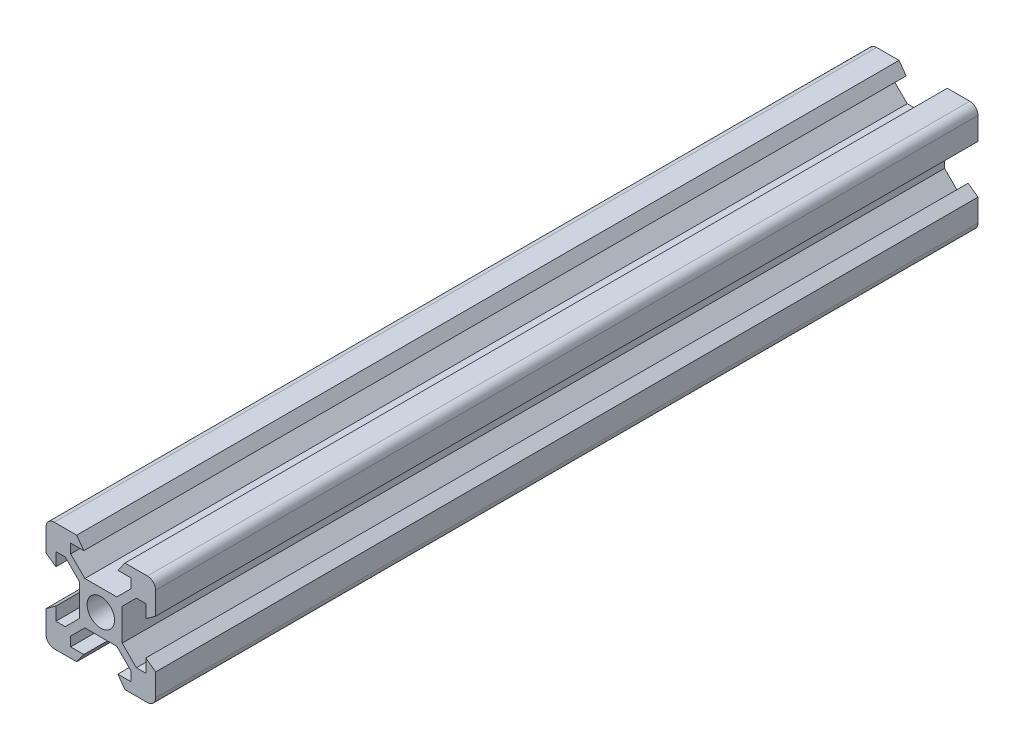
from build123d import *

# Parameters (mm, degrees)
SKETCH_1_R      = 2.5
EXTRUDE_1_DEPTH = 150


with BuildPart() as part:
    # 草图1 → 凸台-拉伸1 (new body)
    with BuildSketch(Plane.XY):
        with BuildLine():
            Line((14.8, 34.821428571), (18.9, 34.821428571))
            Line((18.9, 34.821428571), (20.2, 33.021428571))
            Line((20.2, 33.021428571), (17.8, 33.021428571))
            Line((17.8, 33.021428571), (17.8, 31.311378065))
            Line((17.8, 31.311378065), (20.389949494, 28.721428571))
            Line((20.389949494, 28.721428571), (26.210050506, 28.721428571))
            Line((26.210050506, 28.721428571), (28.8, 31.311378065))
            Line((28.8, 31.311378065), (28.8, 33.021428571))
            Line((28.8, 33.021428571), (26.4, 33.021428571))
            Line((26.4, 33.021428571), (27.7, 34.821428571))
            Line((27.7, 34.821428571), (31.8, 34.821428571))
            ThreePointArc((31.8, 34.821428571), (32.860660172, 34.382088743), (33.3, 33.321428571))
            Line((33.3, 33.321428571), (33.3, 29.221428571))
            Line((33.3, 29.221428571), (31.5, 27.921428571))
            Line((31.5, 27.921428571), (31.5, 30.321428571))
            Line((31.5, 30.321428571), (29.789949494, 30.321428571))
            Line((29.789949494, 30.321428571), (27.2, 27.731479078))
            Line((27.2, 27.731479078), (27.2, 21.911378065))
            Line((27.2, 21.911378065), (29.789949494, 19.321428571))
            Line((29.789949494, 19.321428571), (31.5, 19.321428571))
            Line((31.5, 19.321428571), (31.5, 21.721428571))
            Line((31.5, 21.721428571), (33.3, 20.421428571))
            Line((33.3, 20.421428571), (33.3, 16.321428571))
            ThreePointArc((33.3, 16.321428571), (32.860660172, 15.2607684), (31.8, 14.821428571))
            Line((31.8, 14.821428571), (27.7, 14.821428571))
            Line((27.7, 14.821428571), (26.4, 16.621428571))
            Line((26.4, 16.621428571), (28.8, 16.621428571))
            Line((28.8, 16.621428571), (28.8, 18.331479078))
            Line((28.8, 18.331479078), (26.210050506, 20.921428571))
            Line((26.210050506, 20.921428571), (20.389949494, 20.921428571))
            Line((20.389949494, 20.921428571), (17.8, 18.331479078))
            Line((17.8, 18.331479078), (17.8, 16.621428571))
            Line((17.8, 16.621428571), (20.2, 16.621428571))
            Line((20.2, 16.621428571), (18.9, 14.821428571))
            Line((18.9, 14.821428571), (14.8, 14.821428571))
            ThreePointArc((14.8, 14.821428571), (13.739339828, 15.2607684), (13.3, 16.321428571))
            Line((13.3, 16.321428571), (13.3, 20.421428571))
            Line((13.3, 20.421428571), (15.1, 21.721428571))
            Line((15.1, 21.721428571), (15.1, 19.321428571))
            Line((15.1, 19.321428571), (16.810050506, 19.321428571))
            Line((16.810050506, 19.321428571), (19.4, 21.911378065))
            Line((19.4, 21.911378065), (19.4, 27.731479078))
            Line((19.4, 27.731479078), (16.810050506, 30.321428571))
            Line((16.810050506, 30.321428571), (15.1, 30.321428571))
            Line((15.1, 30.321428571), (15.1, 27.921428571))
            Line((15.1, 27.921428571), (13.3, 29.221428571))
            Line((13.3, 29.221428571), (13.3, 33.321428571))
            ThreePointArc((13.3, 33.321428571), (13.739339828, 34.382088743), (14.8, 34.821428571))
        make_face()
        with Locations((23.3, 24.821428571)):
            Circle(SKETCH_1_R, mode=Mode.SUBTRACT)
    extrude(amount=EXTRUDE_1_DEPTH)


solid = part.part
